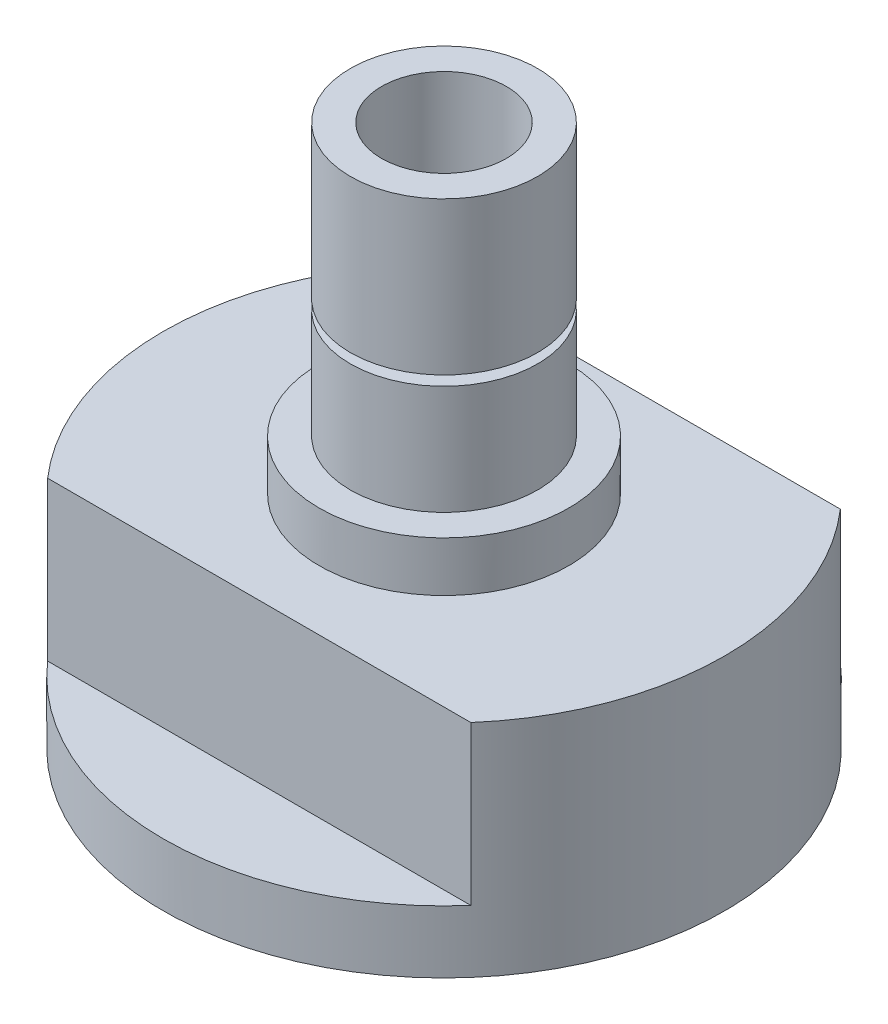
from build123d import *

# Parameters (mm, degrees)
SKETCH1_R           = 12.7
SKETCH1_R_2         = 6.35
BOSS_EXTRUDE1_DEPTH = 5.08
SKETCH2_R           = 9.525
SKETCH2_R_2         = 6.35
BOSS_EXTRUDE2_DEPTH = 27.6225
SKETCH3_OUTSIDE_W   = 37.116
SKETCH3_OUTSIDE_H   = 37.116
SKETCH3_OUTSIDE_R   = 7.4676
CUT_EXTRUDE1_DEPTH  = 0.9906
SKETCH5_R           = 28.575
BOSS_EXTRUDE4_DEPTH = 6.587499906
BOSS_EXTRUDE5_DEPTH = 15.875
SKETCH12_W          = 57.15
SKETCH12_H          = 9.779
CUT_EXTRUDE2_DEPTH  = 16.1125
BOSS_EXTRUDE6_DEPTH = 15.875


with BuildPart() as part:
    # Sketch1 → Boss-Extrude1 (new body)
    with BuildSketch(Plane(origin=(0, 0, 0), x_dir=(1, 0, 0), z_dir=(0, 1, 0))):
        Circle(SKETCH1_R)
        Circle(SKETCH1_R_2, mode=Mode.SUBTRACT)
    extrude(amount=BOSS_EXTRUDE1_DEPTH)

    # Sketch2 → Boss-Extrude2 (add)
    with BuildSketch(Plane(origin=(0, 5.08, 0), x_dir=(1, 0, 0), z_dir=(0, 1, 0))):
        Circle(SKETCH2_R)
        Circle(SKETCH2_R_2, mode=Mode.SUBTRACT)
    extrude(amount=BOSS_EXTRUDE2_DEPTH)

    # Sketch3 outside → Cut-Extrude1 (cut)
    with BuildSketch(Plane(origin=(0, 16.1925, 0), x_dir=(-1, 0, 0), z_dir=(0, 1, 0))):
        Rectangle(SKETCH3_OUTSIDE_W, SKETCH3_OUTSIDE_H)
        Circle(SKETCH3_OUTSIDE_R, mode=Mode.SUBTRACT)
    extrude(amount=CUT_EXTRUDE1_DEPTH, mode=Mode.SUBTRACT)

    # Sketch5 → Boss-Extrude4 (add)
    with BuildSketch(Plane.XZ):
        Circle(SKETCH5_R)
    extrude(amount=BOSS_EXTRUDE4_DEPTH)

    # Sketch8 → Boss-Extrude5 (add)
    with BuildSketch(Plane.XZ.offset(6.587499906)):
        with BuildLine():
            Line((23.759524406, -15.875), (-23.759524406, -15.875))
            ThreePointArc((-23.759524406, -15.875), (0, -28.575), (23.759524406, -15.875))
        make_face()
        with BuildLine():
            ThreePointArc((23.759524406, 15.875), (0, 28.575), (-23.759524406, 15.875))
            Line((-23.759524406, 15.875), (23.759524406, 15.875))
        make_face()
    extrude(amount=BOSS_EXTRUDE5_DEPTH)

    # Sketch12 → Cut-Extrude2 (cut)
    with BuildSketch(Plane(origin=(0, 0, 0), x_dir=(1, 0, 0), z_dir=(0, 1, 0))):
        with Locations((0, 23.6855)):
            Rectangle(SKETCH12_W, SKETCH12_H)
        with Locations((0, -23.6855)):
            Rectangle(SKETCH12_W, SKETCH12_H)
    extrude(amount=-CUT_EXTRUDE2_DEPTH, mode=Mode.SUBTRACT)

    # Sketch13 → Boss-Extrude6 (add)
    with BuildSketch(Plane.XZ.offset(6.587499906)):
        with BuildLine():
            Line((23.759524406, 15.875), (-23.759524406, 15.875))
            ThreePointArc((-23.759524406, 15.875), (-28.575, 0), (-23.759524406, -15.875))
            Line((-23.759524406, -15.875), (23.759524406, -15.875))
            ThreePointArc((23.759524406, -15.875), (28.575, 0), (23.759524406, 15.875))
        make_face()
    extrude(amount=BOSS_EXTRUDE6_DEPTH)


solid = part.part
